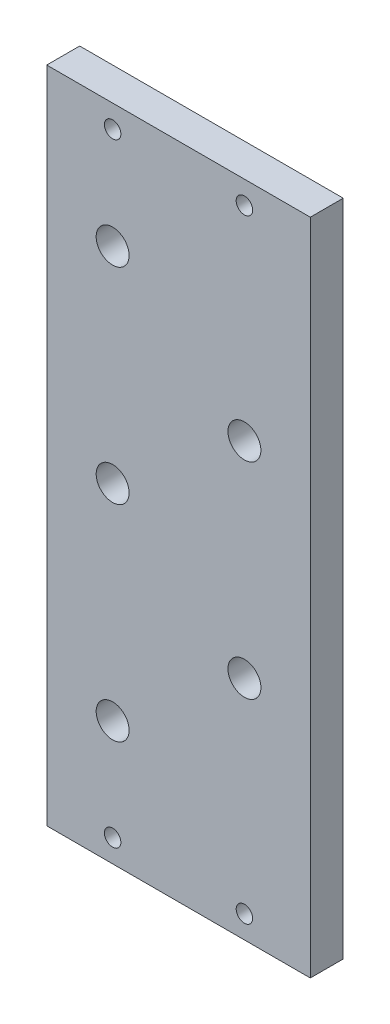
from build123d import *

# Parameters (mm, degrees)
SKETCH1_W           = 101.6
SKETCH1_H           = 254
BOSS_EXTRUDE1_DEPTH = 12.7
SKETCH2_R           = 6.35
SKETCH2_R_2         = 3.175
CUT_EXTRUDE1_DEPTH  = 13.7


with BuildPart() as part:
    # Sketch1 → Boss-Extrude1 (new body)
    with BuildSketch(Plane.XY):
        with Locations((50.8, 127)):
            Rectangle(SKETCH1_W, SKETCH1_H)
    extrude(amount=BOSS_EXTRUDE1_DEPTH)

    # Sketch2 → Cut-Extrude1 (cut, through all)
    with BuildSketch(Plane.XY.offset(12.7)):
        with Locations((25.4, 47.752)):
            Circle(SKETCH2_R)
        with Locations((76.2, 87.376)):
            Circle(SKETCH2_R)
        with Locations((25.4, 127)):
            Circle(SKETCH2_R)
        with Locations((76.2, 166.624)):
            Circle(SKETCH2_R)
        with Locations((25.4, 206.248)):
            Circle(SKETCH2_R)
        with Locations((25.4, 8.763)):
            Circle(SKETCH2_R_2)
        with Locations((76.2, 8.763)):
            Circle(SKETCH2_R_2)
        with Locations((25.4, 245.237)):
            Circle(SKETCH2_R_2)
        with Locations((76.2, 245.237)):
            Circle(SKETCH2_R_2)
    extrude(amount=-CUT_EXTRUDE1_DEPTH, mode=Mode.SUBTRACT)


solid = part.part
